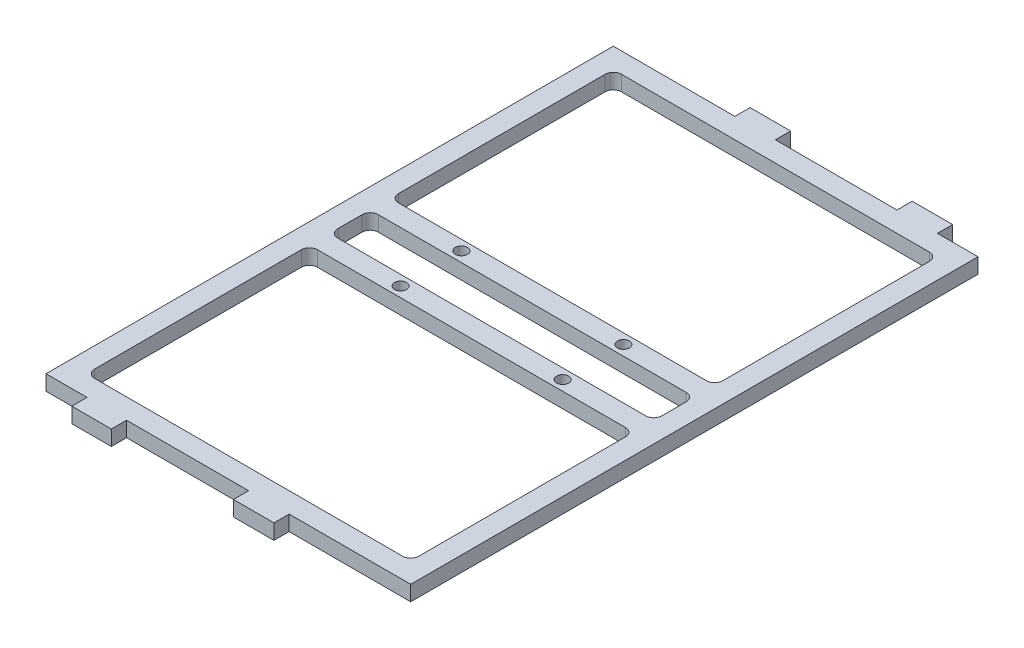
from build123d import *

# Parameters (mm, degrees)
SKETCH1_W                 = 114.3
SKETCH1_H                 = 177.8
SKETCH1_W_2               = 101.6
SKETCH1_H_2               = 165.1
BOSS_EXTRUDE1_DEPTH       = 4.7625
SKETCH2_W                 = 12.38677804
SKETCH2_H                 = 4.7625
SKETCH2_W_2               = 12.7
BOSS_EXTRUDE2_DEPTH       = 4.7625
SKETCH3_W                 = 12.7
SKETCH3_H                 = 4.7625
BOSS_EXTRUDE3_DEPTH       = 4.7625
FILLET1_R                 = 2.54
SKETCH4_W                 = 101.6
SKETCH4_H                 = 6.35
SKETCH4_W_2               = 114.3
BOSS_EXTRUDE4_DEPTH       = 4.7625
FILLET2_R                 = 2.54
F_6_CLEARANCE_HOLE1_D     = 3.7973
F_6_CLEARANCE_HOLE1_DEPTH = 25.4
F_6_CLEARANCE_HOLE1_TIP   = 1.140824014


with BuildPart() as part:
    # Sketch1 → Boss-Extrude1 (new body)
    with BuildSketch(Plane(origin=(0, 0, 0), x_dir=(1, 0, 0), z_dir=(0, 1, 0))):
        Rectangle(SKETCH1_W, SKETCH1_H)
        Rectangle(SKETCH1_W_2, SKETCH1_H_2, mode=Mode.SUBTRACT)
    extrude(amount=BOSS_EXTRUDE1_DEPTH)

    # Sketch2 → Boss-Extrude2 (add)
    with BuildSketch(Plane.XY.offset(88.9)):
        with Locations((-38.1, 2.38125)):
            Rectangle(SKETCH2_W, SKETCH2_H)
        with Locations((12.7, 2.38125)):
            Rectangle(SKETCH2_W_2, SKETCH2_H)
    extrude(amount=BOSS_EXTRUDE2_DEPTH)

    # Sketch3 → Boss-Extrude3 (add)
    with BuildSketch(Plane(origin=(0, 0, -88.9), x_dir=(-1, 0, 0), z_dir=(0, 0, -1))):
        with Locations((-38.1, 2.38125)):
            Rectangle(SKETCH3_W, SKETCH3_H)
        with Locations((12.7, 2.38125)):
            Rectangle(SKETCH3_W, SKETCH3_H)
    extrude(amount=BOSS_EXTRUDE3_DEPTH)

    # Fillet1
    fillet1_edges = [part.edges().sort_by_distance(p)[0] for p in [
        (50.8, 2.38125, 82.55),
        (50.8, 2.38125, -82.55),
        (-50.8, 2.38125, -82.55),
        (-50.8, 2.38125, 82.55),
    ]]
    fillet(fillet1_edges, radius=FILLET1_R)

    # Sketch4 → Boss-Extrude4 (add)
    with BuildSketch(Plane(origin=(0, 4.7625, 0), x_dir=(1, 0, 0), z_dir=(0, 1, 0))):
        with Locations((0, 9.525)):
            Rectangle(SKETCH4_W, SKETCH4_H)
        with Locations((0, -9.525)):
            Rectangle(SKETCH4_W_2, SKETCH4_H)
    extrude(amount=-BOSS_EXTRUDE4_DEPTH)

    # Fillet2
    fillet2_edges = [part.edges().sort_by_distance(p)[0] for p in [
        (-50.8, 2.38125, -6.35),
        (-50.8, 2.38125, -12.7),
        (50.8, 2.38125, -12.7),
        (50.8, 2.38125, -6.35),
        (-50.8, 2.38125, 12.7),
        (-50.8, 2.38125, 6.35),
        (50.8, 2.38125, 6.35),
        (50.8, 2.38125, 12.7),
    ]]
    fillet(fillet2_edges, radius=FILLET2_R)

    # #6 Clearance Hole1
    with Locations(Plane(origin=(0, 4.7625, 0), x_dir=(-1, 0, 0), z_dir=(0, 1, 0))):
        with Locations((25.4, -9.525), (25.4, 9.525), (-25.4, 9.525), (-25.4, -9.525)):
            Hole(F_6_CLEARANCE_HOLE1_D / 2, depth=F_6_CLEARANCE_HOLE1_DEPTH)
            with Locations((0, 0, -(F_6_CLEARANCE_HOLE1_DEPTH + F_6_CLEARANCE_HOLE1_TIP / 2))):  # 118° drill point
                Cone(0, F_6_CLEARANCE_HOLE1_D / 2, F_6_CLEARANCE_HOLE1_TIP, mode=Mode.SUBTRACT)


solid = part.part
